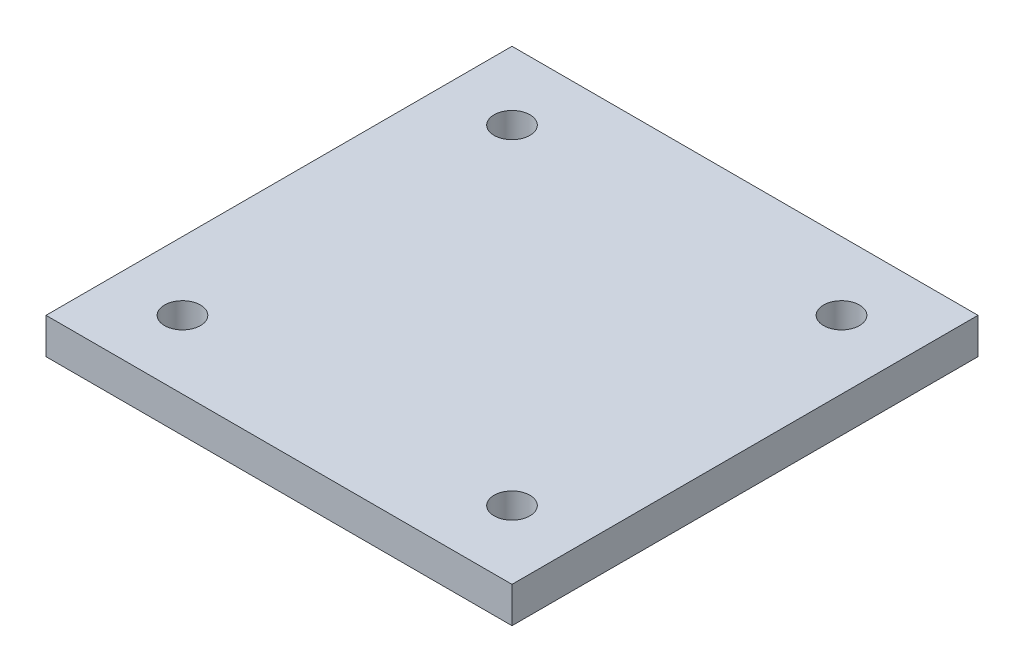
from build123d import *

# Parameters (mm, degrees)
SKETCH1_W           = 65
SKETCH1_H           = 65
SKETCH1_R           = 2.5
BOSS_EXTRUDE1_DEPTH = 5


with BuildPart() as part:
    # Sketch1 → Boss-Extrude1 (new body)
    with BuildSketch(Plane(origin=(0, 0, 0), x_dir=(1, 0, 0), z_dir=(0, 1, 0))):
        Rectangle(SKETCH1_W, SKETCH1_H)
        with Locations((22.980970389, -22.980970389)):
            Circle(SKETCH1_R, mode=Mode.SUBTRACT)
        with Locations((-22.980970389, -22.980970389)):
            Circle(SKETCH1_R, mode=Mode.SUBTRACT)
        with Locations((-22.980970389, 22.980970389)):
            Circle(SKETCH1_R, mode=Mode.SUBTRACT)
        with Locations((22.980970389, 22.980970389)):
            Circle(SKETCH1_R, mode=Mode.SUBTRACT)
    extrude(amount=BOSS_EXTRUDE1_DEPTH)


solid = part.part
